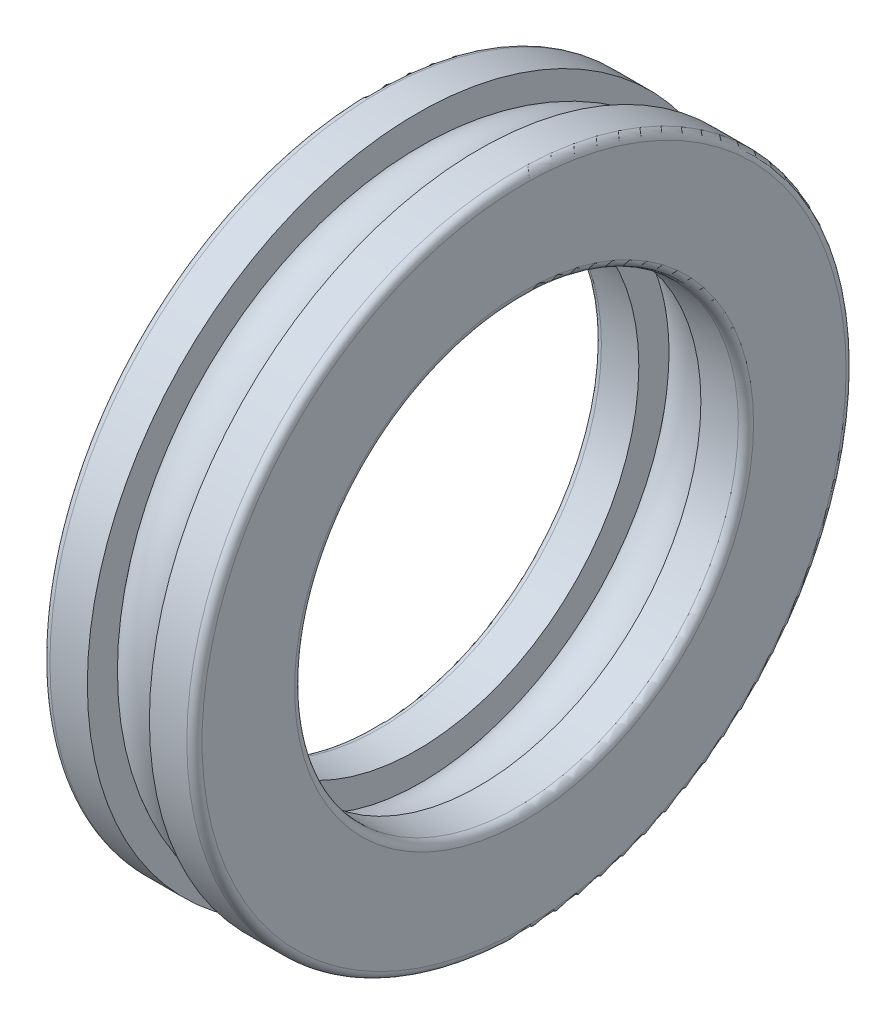
from build123d import *

# Parameters (mm, degrees)
BALSIMSKE_R = 3.06


with BuildPart() as part:
    # InnRacSke → Race (revolve)
    with BuildSketch(Plane.XY):
        with BuildLine():
            Line((-2.448, 19.95597631), (-2.448, 17.5))
            Line((-2.448, 17.5), (-5.4, 17.5))
            ThreePointArc((-5.4, 17.5), (-5.824264069, 17.675735931), (-6, 18.1))
            Line((-6, 18.1), (-6, 25.4))
            ThreePointArc((-6, 25.4), (-5.824264069, 25.824264069), (-5.4, 26))
            Line((-5.4, 26), (-2.448, 26))
            Line((-2.448, 26), (-2.448, 23.54402369))
            ThreePointArc((-2.448, 23.54402369), (-3.035, 21.75), (-2.448, 19.95597631))
        make_face()
    race = revolve(axis=Axis((-34.925, 0, 0), (1, 0, 0)))

    # BalSimSke → BallsSimplified (revolve)
    with BuildSketch(Plane.XY):
        with Locations((0, 21.75)):
            Circle(BALSIMSKE_R)
    revolve(axis=Axis((-25.4, 0, 0), (1, 0, 0)))

    # Mirror1: Race across plane
    add(race.mirror(Plane(origin=(0, 0, 0), x_dir=(0, 0, 1), z_dir=(1, 0, 0))))


solid = part.part
